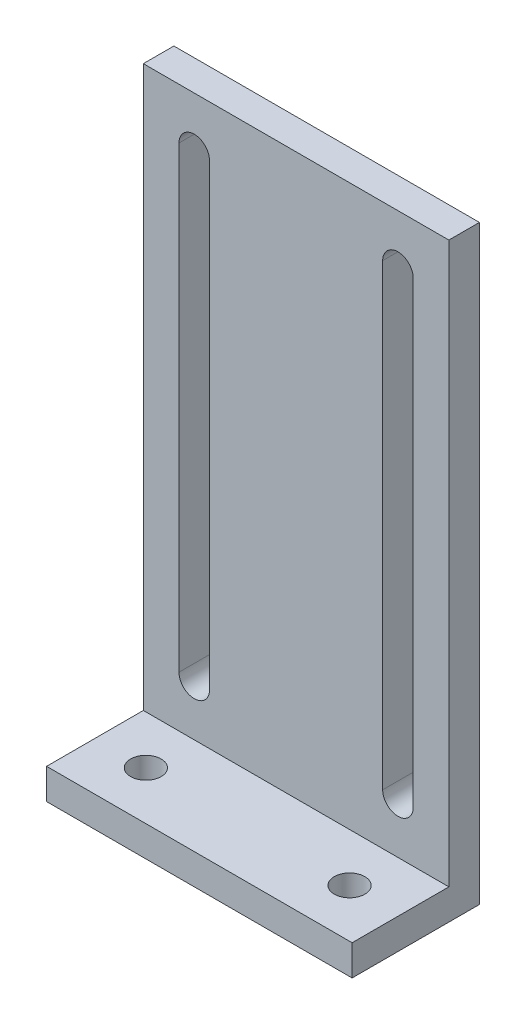
from build123d import *

# Parameters (mm, degrees)
SKETCH1_W           = 30
SKETCH1_H           = 12.5
BOSS_EXTRUDE1_DEPTH = 3
SKETCH2_W           = 30
SKETCH2_H           = 3
BOSS_EXTRUDE2_DEPTH = 55
CUT_EXTRUDE1_DEPTH  = 4
SKETCH4_R           = 1.5
CUT_EXTRUDE2_DEPTH  = 4


with BuildPart() as part:
    # Sketch1 → Boss-Extrude1 (new body)
    with BuildSketch(Plane(origin=(0, 0, 0), x_dir=(1, 0, 0), z_dir=(0, 1, 0))):
        Rectangle(SKETCH1_W, SKETCH1_H)
    extrude(amount=BOSS_EXTRUDE1_DEPTH)

    # Sketch2 → Boss-Extrude2 (add)
    with BuildSketch(Plane(origin=(0, 3, 0), x_dir=(1, 0, 0), z_dir=(0, 1, 0))):
        with Locations((0, 4.75)):
            Rectangle(SKETCH2_W, SKETCH2_H)
    extrude(amount=BOSS_EXTRUDE2_DEPTH)

    # Sketch3 → Cut-Extrude1 (cut, through all)
    with BuildSketch(Plane.XY.offset(-3.25)):
        with BuildLine():
            Line((-8.5, 53), (-8.5, 8))
            ThreePointArc((-8.5, 8), (-10, 6.5), (-11.5, 8))
            Line((-11.5, 8), (-11.5, 53))
            ThreePointArc((-11.5, 53), (-10, 54.5), (-8.5, 53))
        make_face()
        with BuildLine():
            Line((8.5, 53), (8.5, 8))
            ThreePointArc((8.5, 8), (10, 6.5), (11.5, 8))
            Line((11.5, 8), (11.5, 53))
            ThreePointArc((11.5, 53), (10, 54.5), (8.5, 53))
        make_face()
    extrude(amount=-CUT_EXTRUDE1_DEPTH, mode=Mode.SUBTRACT)

    # Sketch4 → Cut-Extrude2 (cut, through all)
    with BuildSketch(Plane(origin=(0, 3, 0), x_dir=(1, 0, 0), z_dir=(0, 1, 0))):
        with Locations((-10, -1.5)):
            Circle(SKETCH4_R)
        with Locations((10, -1.5)):
            Circle(SKETCH4_R)
    extrude(amount=-CUT_EXTRUDE2_DEPTH, mode=Mode.SUBTRACT)


solid = part.part
